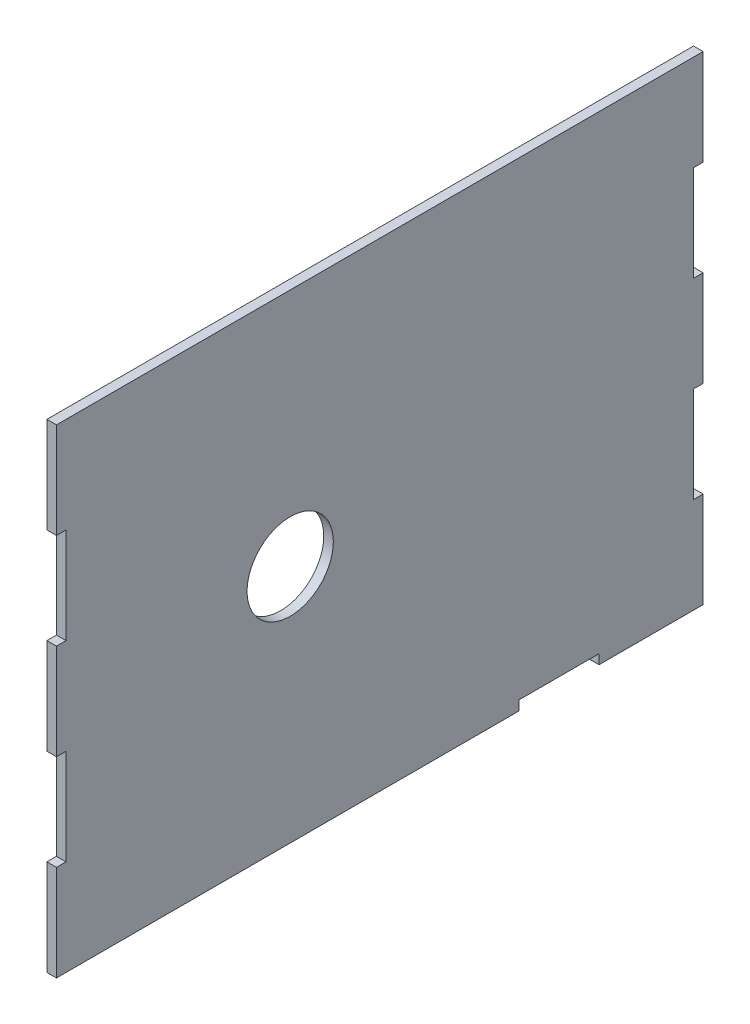
from build123d import *

# Parameters (mm, degrees)
SKETCH1_W           = 171.45
SKETCH1_H           = 127
BOSS_EXTRUDE1_DEPTH = 2.54
SKETCH2_W           = 2.54
SKETCH2_H           = 25.4
CUT_EXTRUDE1_DEPTH  = 3.54
SKETCH3_R           = 11.43
CUT_EXTRUDE2_DEPTH  = 3.54
SKETCH4_W           = 21.166666667
SKETCH4_H           = 2.54
CUT_EXTRUDE3_DEPTH  = 3.54


with BuildPart() as part:
    # Sketch1 → Boss-Extrude1 (new body)
    with BuildSketch(Plane(origin=(0, 0, 0), x_dir=(0, 0, -1), z_dir=(1, 0, 0))):
        with Locations((85.725, 63.5)):
            Rectangle(SKETCH1_W, SKETCH1_H)
    extrude(amount=BOSS_EXTRUDE1_DEPTH)

    # Sketch2 → Cut-Extrude1 (cut, through all)
    with BuildSketch(Plane(origin=(2.54, 0, 0), x_dir=(0, 0, -1), z_dir=(1, 0, 0))):
        with Locations((1.27, 88.9)):
            Rectangle(SKETCH2_W, SKETCH2_H)
        with Locations((1.27, 38.1)):
            Rectangle(SKETCH2_W, SKETCH2_H)
        with Locations((170.18, 88.9)):
            Rectangle(SKETCH2_W, SKETCH2_H)
        with Locations((170.18, 38.1)):
            Rectangle(SKETCH2_W, SKETCH2_H)
    extrude(amount=-CUT_EXTRUDE1_DEPTH, mode=Mode.SUBTRACT)

    # Sketch3 → Cut-Extrude2 (cut, through all)
    with BuildSketch(Plane(origin=(2.54, 0, 0), x_dir=(0, 0, -1), z_dir=(1, 0, 0))):
        with Locations((61.976, 63.5)):
            Circle(SKETCH3_R)
    extrude(amount=-CUT_EXTRUDE2_DEPTH, mode=Mode.SUBTRACT)

    # Sketch4 → Cut-Extrude3 (cut, through all)
    with BuildSketch(Plane(origin=(2.54, 0, 0), x_dir=(0, 0, -1), z_dir=(1, 0, 0))):
        with Locations((133.265333333, 1.27)):
            Rectangle(SKETCH4_W, SKETCH4_H)
    extrude(amount=-CUT_EXTRUDE3_DEPTH, mode=Mode.SUBTRACT)


solid = part.part
